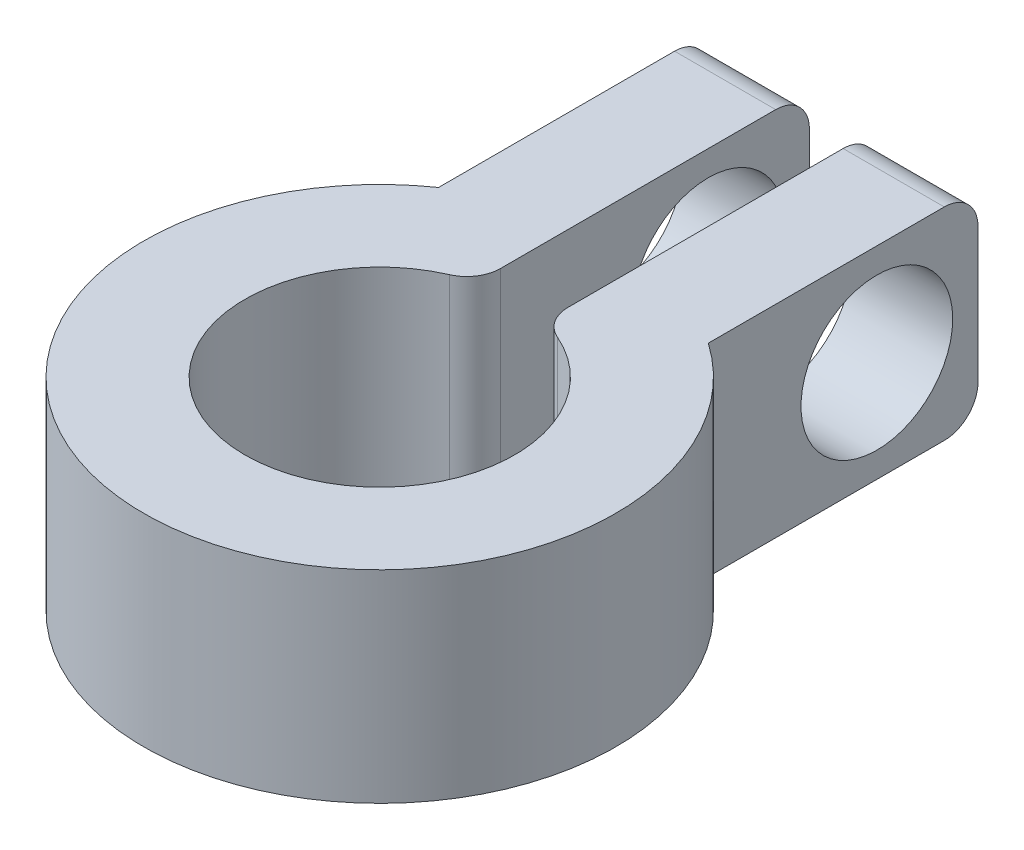
from build123d import *

# Parameters (mm, degrees)
BOSS_EXTRUDE1_DEPTH = 6
SKETCH3_R           = 2.25
CUT_EXTRUDE1_DEPTH  = 10
FILLET1_R           = 1


with BuildPart() as part:
    # Sketch2 → Boss-Extrude1 (new body)
    with BuildSketch(Plane(origin=(0, 0, 0), x_dir=(1, 0, 0), z_dir=(0, 1, 0))):
        with BuildLine():
            Line((-1, 3.872983346), (-1, 13.744562647))
            Line((-1, 13.744562647), (-4, 13.744562647))
            Line((-4, 13.744562647), (-4, 5.744562647))
            ThreePointArc((-4, 5.744562647), (0, -7), (4, 5.744562647))
            Line((4, 5.744562647), (4, 13.744562647))
            Line((4, 13.744562647), (1, 13.744562647))
            Line((1, 13.744562647), (1, 3.872983346))
            ThreePointArc((1, 3.872983346), (0, -4), (-1, 3.872983346))
        make_face()
    extrude(amount=BOSS_EXTRUDE1_DEPTH)

    # Sketch3 → Cut-Extrude1 (cut)
    with BuildSketch(Plane(origin=(4, 0, 0), x_dir=(0, 0, -1), z_dir=(1, 0, 0))):
        with Locations((10.744562647, 3)):
            Circle(SKETCH3_R)
    extrude(amount=-CUT_EXTRUDE1_DEPTH, mode=Mode.SUBTRACT)

    # Fillet1
    fillet1_edges = [part.edges().sort_by_distance(p)[0] for p in [
        (-2.5, 0, -13.744562647),
        (-2.5, 6, -13.744562647),
        (1, 3, -3.872983346),
        (-1, 3, -3.872983346),
        (2.5, 6, -13.744562647),
        (2.5, 0, -13.744562647),
    ]]
    fillet(fillet1_edges, radius=FILLET1_R)


solid = part.part
